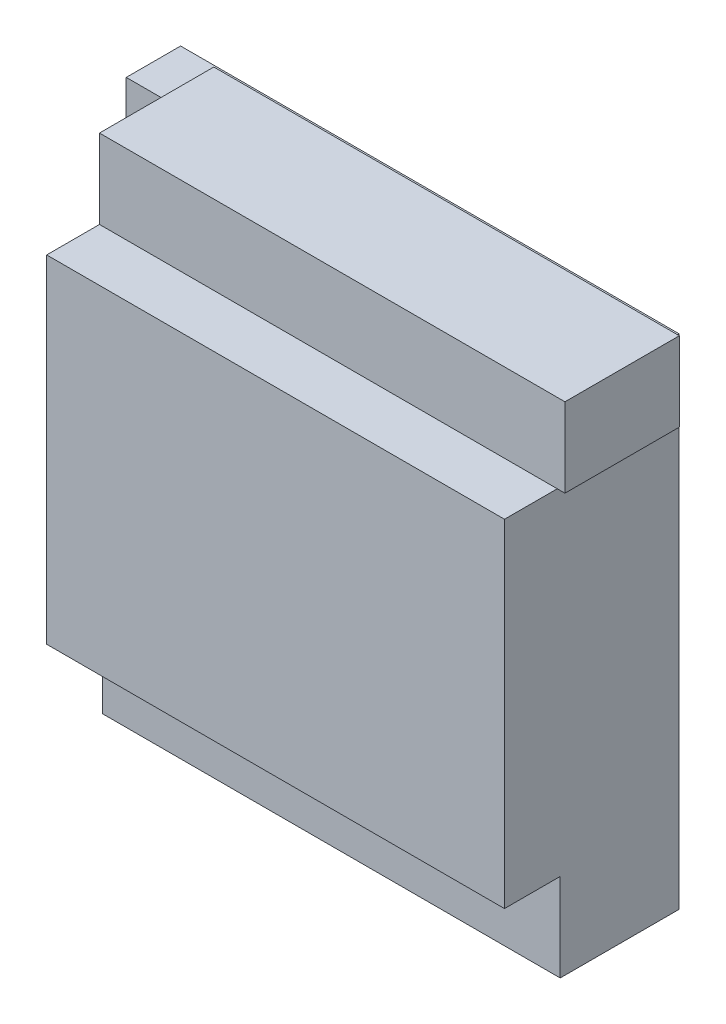
from build123d import *

# Parameters (mm, degrees)
SKETCH1_W           = 170
SKETCH1_H           = 170
SKETCH1_R           = 1.98
BOSS_EXTRUDE1_DEPTH = 2.54
SKETCH2_W           = 158.75
SKETCH2_H           = 27
BOSS_EXTRUDE2_DEPTH = 39
SKETCH4_W           = 13.87
SKETCH4_H           = 170
BOSS_EXTRUDE3_DEPTH = 16
SKETCH6_W           = 156.13
SKETCH6_H           = 30
BOSS_EXTRUDE4_DEPTH = 38
SKETCH5_W           = 156.13
SKETCH5_H           = 115
BOSS_EXTRUDE5_DEPTH = 57


with BuildPart() as part:
    # Sketch1 → Boss-Extrude1 (new body)
    with BuildSketch(Plane.XY):
        Rectangle(SKETCH1_W, SKETCH1_H)
        with Locations((-78.65, 74.84)):
            Circle(SKETCH1_R, mode=Mode.SUBTRACT)
        with Locations((78.83, 51.98)):
            Circle(SKETCH1_R, mode=Mode.SUBTRACT)
        with Locations((-78.65, -80.1)):
            Circle(SKETCH1_R, mode=Mode.SUBTRACT)
        with Locations((78.83, -80.1)):
            Circle(SKETCH1_R, mode=Mode.SUBTRACT)
    extrude(amount=BOSS_EXTRUDE1_DEPTH)

    # Sketch2 → Boss-Extrude2 (add)
    with BuildSketch(Plane.XY.offset(2.54)):
        with Locations((8.245, 73.5)):
            Rectangle(SKETCH2_W, SKETCH2_H)
    extrude(amount=BOSS_EXTRUDE2_DEPTH)

    # Sketch4 → Boss-Extrude3 (add)
    with BuildSketch(Plane.XY.offset(2.54)):
        with Locations((-78.065, 0)):
            Rectangle(SKETCH4_W, SKETCH4_H)
    extrude(amount=BOSS_EXTRUDE3_DEPTH)

    # Sketch6 → Boss-Extrude4 (add)
    with BuildSketch(Plane.XY.offset(2.54)):
        with Locations((6.935, -70)):
            Rectangle(SKETCH6_W, SKETCH6_H)
    extrude(amount=BOSS_EXTRUDE4_DEPTH)

    # Sketch5 → Boss-Extrude5 (add)
    with BuildSketch(Plane.XY.offset(2.54)):
        with Locations((6.935, 2.5)):
            Rectangle(SKETCH5_W, SKETCH5_H)
    extrude(amount=BOSS_EXTRUDE5_DEPTH)


solid = part.part
